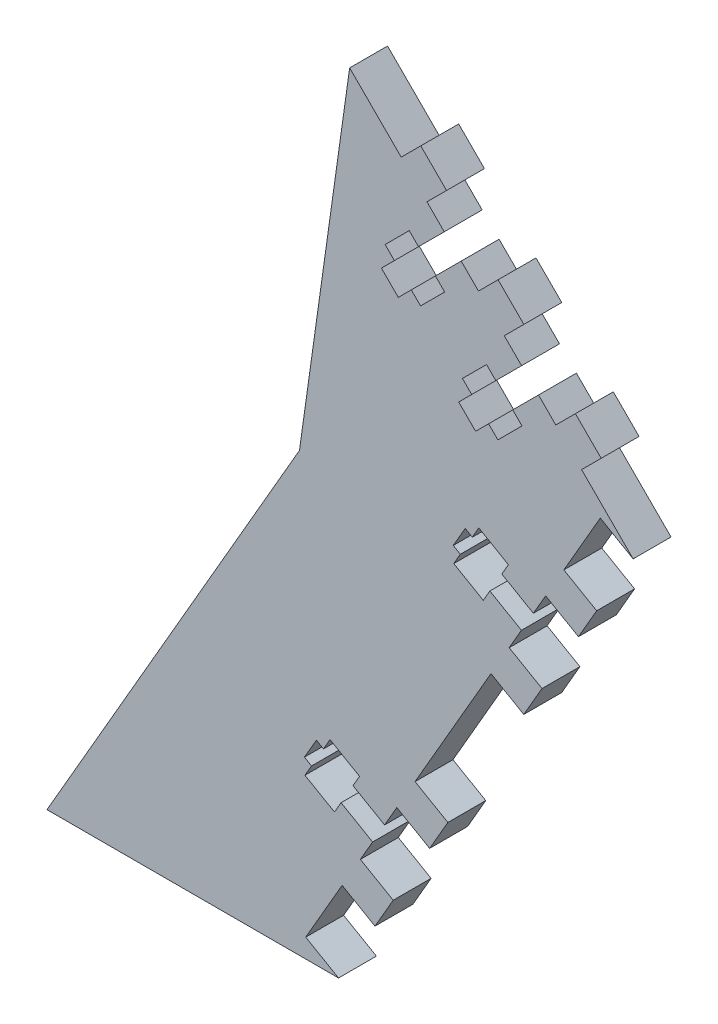
from build123d import *

# Parameters (mm, degrees)
BOSS_EXTRUDE1_DEPTH = 6.604
MOVE_FACE2_BY       = 0.00254
CUT_EXTRUDE1_DEPTH  = 374.058010856
CUT_EXTRUDE2_DEPTH  = 257.166060573
CUT_EXTRUDE3_DEPTH  = 257.166060573
BOSS_EXTRUDE2_DEPTH = 6.604


with BuildPart() as part:
    # Sketch1 → Boss-Extrude1 (new body)
    with BuildSketch(Plane.XY):
        Polygon((0, 304.426146906), (215.526146906, 88.9), (164.199707975, 0), (0, 0), (-164.199707975, 0), (-215.526146906, 88.9), align=None)
    extrude(amount=BOSS_EXTRUDE1_DEPTH)

    # Move Face2: a face moved outward by 0.00254
    extrude(part.faces().sort_by_distance((107.763073453, 196.663073453, 3.302))[0], amount=MOVE_FACE2_BY, dir=(0.707106781, 0.707106781, 0))

    # Sketch2 → Cut-Extrude1 (cut, through all)
    with BuildSketch(Plane.XY.offset(6.604)):
        Polygon((113.399707975, 0), (157.393798487, 76.2), (166.136053041, 138.293685968), (0.001796051, 304.427942957), (-215.526146906, 88.9), (-164.199707975, 0), align=None)
    extrude(amount=-CUT_EXTRUDE1_DEPTH, mode=Mode.SUBTRACT)

    # Sketch3 → Cut-Extrude2 (cut, through all)
    with BuildSketch(Plane.XY.offset(6.604)):
        Polygon((158.480476208, 3.302), (209.806915139, 92.202), (215.526146906, 88.9), (164.199707975, 0), align=None)
    extrude(amount=-CUT_EXTRUDE2_DEPTH, mode=Mode.SUBTRACT)

    # Sketch5 → Cut-Extrude3 (cut, through all)
    with BuildSketch(Plane.XY.offset(6.604)):
        Polygon((182.623803279, 121.805935729), (178.133675218, 117.315807669), (176.517229116, 118.932253771), (172.314469252, 114.729493906), (173.930915354, 113.113047804), (171.667890811, 110.850023262), (174.613414819, 107.904499254), (176.876439361, 110.167523796), (178.492885463, 108.551077695), (182.695645328, 112.753837559), (181.079199226, 114.370283661), (185.569327287, 118.860411722), align=None)
        Polygon((194.549583408, 100.899899479), (199.039711468, 105.39002754), (196.09418746, 108.335551548), (191.6040594, 103.845423487), (189.987613298, 105.461869589), (185.784853433, 101.259109724), (187.401299535, 99.642663622), (185.138274993, 97.37963908), (188.083799, 94.434115072), (190.346823543, 96.697139615), (191.963269645, 95.080693513), (196.166029509, 99.283453378), align=None)
        Polygon((198.148315139, 72.008712455), (192.649053825, 75.183712455), (193.792053825, 77.163446528), (188.644745235, 80.135246528), (187.501745235, 78.155512455), (186.269910701, 78.866712455), (184.187110701, 75.259197033), (185.418945235, 74.547997033), (184.275945235, 72.56826296), (189.423253825, 69.59646296), (190.566253825, 71.576197033), (196.065515139, 68.401197033), align=None)
        Polygon((172.221876208, 27.102802967), (166.722614894, 30.277802967), (167.865614894, 32.25753704), (162.718306304, 35.22933704), (161.575306304, 33.249602967), (160.34347177, 33.960802967), (158.26067177, 30.353287545), (159.492506304, 29.642087545), (158.349506304, 27.662353472), (163.496814894, 24.690553472), (164.639814894, 26.670287545), (170.139076208, 23.495287545), align=None)
    extrude(amount=-CUT_EXTRUDE3_DEPTH, mode=Mode.SUBTRACT)

    # Sketch6 → Boss-Extrude2 (add)
    with BuildSketch(Plane.XY.offset(6.604)):
        Polygon((178.528806488, 132.725927173), (175.116309162, 129.313429847), (179.606437222, 124.823301786), (183.018934548, 128.235799112), align=None)
        Polygon((188.586693343, 115.843045665), (191.999190669, 119.255542991), (196.48931873, 114.76541493), (193.076821404, 111.352917604), align=None)
        Polygon((205.469574851, 105.785158809), (209.959702911, 101.295030749), (206.547205585, 97.882533423), (202.057077525, 102.372661483), align=None)
        Polygon((209.176146906, 77.901477372), (203.456915139, 81.203477372), (200.281915139, 75.704216058), (206.001146906, 72.402216058), align=None)
        Polygon((193.931915139, 64.70569343), (199.651146906, 61.40369343), (196.476146906, 55.904432116), (190.756915139, 59.206432116), align=None)
        Polygon((183.249707975, 32.995567884), (177.530476208, 36.297567884), (174.355476208, 30.79830657), (180.074707975, 27.49630657), align=None)
        Polygon((168.005476208, 19.799783942), (173.724707975, 16.497783942), (170.549707975, 10.998522628), (164.830476208, 14.300522628), align=None)
    extrude(amount=-BOSS_EXTRUDE2_DEPTH)


solid = part.part
